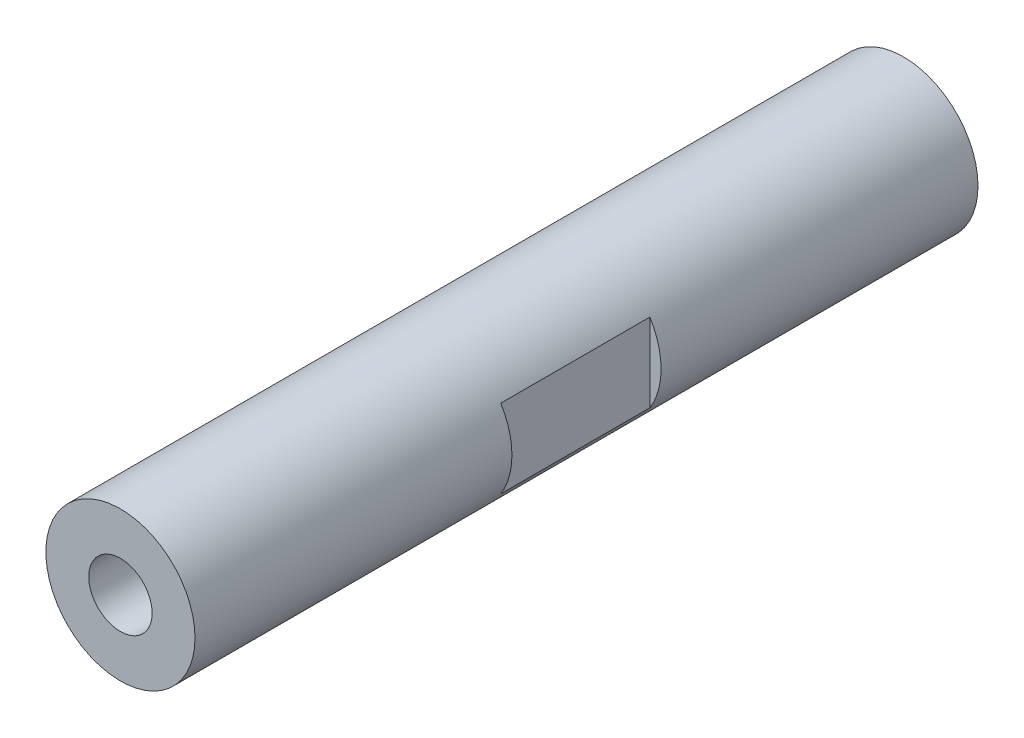
from build123d import *

# Parameters (mm, degrees)
SKETCH_1_R          = 10
EXTRUDE_1_DEPTH     = 52.5
SKETCH_2_W          = 3
SKETCH_2_H          = 20
CUT_EXTRUDE_1_DEPTH = 30


with BuildPart() as part:
    # 草图1 → 凸台-拉伸1 (new body, symmetric)
    with BuildSketch(Plane.XY):
        Circle(SKETCH_1_R)
    extrude(amount=EXTRUDE_1_DEPTH, both=True)

    # 草图2 → 切除-拉伸1 (cut, symmetric)
    with BuildSketch(Plane(origin=(0, 0, 0), x_dir=(1, 0, 0), z_dir=(0, 1, 0))):
        with Locations((-10, 0)):
            Rectangle(SKETCH_2_W, SKETCH_2_H)
        with Locations((10, 0)):
            Rectangle(SKETCH_2_W, SKETCH_2_H)
    extrude(amount=CUT_EXTRUDE_1_DEPTH, both=True, mode=Mode.SUBTRACT)

    # 草图4 → M10 螺纹孔1 (revolve, cut)
    with BuildSketch(Plane(origin=(0, 0, 52.5), x_dir=(0, -1, 0), z_dir=(1, 0, 0))):
        Polygon((0, 0), (0, 27.053657631), (4.25, 24.5), (4.25, 0), align=None)
    hole_wizard_m10_1 = revolve(axis=Axis((0, 0, 58.85), (0, 0, -1)), mode=Mode.SUBTRACT)

    # 镜向1: M10 螺纹孔1 across plane
    add(hole_wizard_m10_1.mirror(Plane.XY), mode=Mode.SUBTRACT)


solid = part.part
